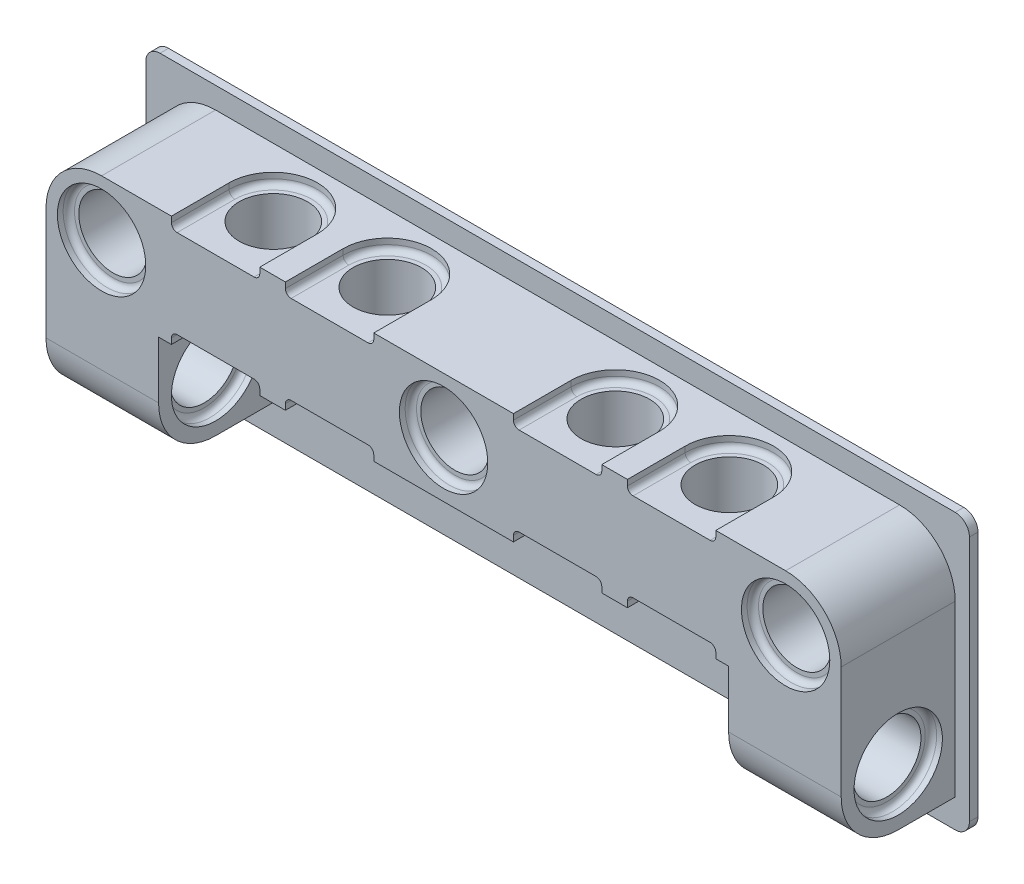
from build123d import *

# Parameters (mm, degrees)
SKETCH1_R               = 2.4
BOSS_EXTRUDE1_DEPTH     = 8
BOSS_EXTRUDE2_START     = 20
SKETCH2_R               = 2.4
BOSS_EXTRUDE2_DEPTH     = 7.9
BOSS_EXTRUDE3_DEPTH     = 0.6
SKETCH4_R               = 2.4
CUT_EXTRUDE1_DEPTH      = 34.051777562
CUT_EXTRUDE1_DEPTH_BACK = 34.051777562
CUT_EXTRUDE2_START      = 3.1
SKETCH5_R               = 3.1
CUT_EXTRUDE2_DEPTH      = 0.8
CUT_EXTRUDE3_START      = -3.9
SKETCH5_3_R             = 3.1
CUT_EXTRUDE3_DEPTH      = 0.8
CUT_EXTRUDE4_START      = 27.9
SKETCH6_R               = 3.1
CUT_EXTRUDE4_DEPTH      = 0.8
CUT_EXTRUDE5_START      = 20
SKETCH6_2_R             = 3.1
CUT_EXTRUDE5_DEPTH      = 0.8
CUT_EXTRUDE6_START      = 0.8
SKETCH7_R               = 3.1
CUT_EXTRUDE6_DEPTH      = 34.851777562
CUT_EXTRUDE7_START      = 7.2
SKETCH7_2_R             = 3.1
CUT_EXTRUDE7_DEPTH      = 0.8
FILLET1_R               = 0.4


with BuildPart() as part:
    # Sketch1 → Boss-Extrude1 (new body)
    with BuildSketch(Plane.XY):
        with BuildLine():
            Line((0, 3.9), (0, 2.4))
            ThreePointArc((0, 2.4), (2.4, 0), (0, -2.4))
            Line((0, -2.4), (0, -3.9))
            Line((0, -3.9), (24, -3.9))
            Line((24, -3.9), (27.9, -3.9))
            Line((27.9, -3.9), (27.9, 0))
            ThreePointArc((27.9, 0), (26.757716447, 2.757716447), (24, 3.9))
            Line((24, 3.9), (0, 3.9))
        make_face()
        with Locations((24, 0)):
            Circle(SKETCH1_R, mode=Mode.SUBTRACT)
    extrude(amount=BOSS_EXTRUDE1_DEPTH)

    # Sketch2 → Boss-Extrude2 (add)
    with BuildSketch(Plane(origin=(0, 0, 0), x_dir=(0, 0, -1), z_dir=(1, 0, 0)).offset(BOSS_EXTRUDE2_START)):
        with BuildLine():
            Line((0, -3.9), (0, -11.9))
            Line((0, -11.9), (-4, -11.9))
            ThreePointArc((-4, -11.9), (-6.828427125, -10.728427125), (-8, -7.9))
            Line((-8, -7.9), (-8, -3.9))
            Line((-8, -3.9), (0, -3.9))
        make_face()
        with Locations(Location((-4, -7.9, 0), (0, 0, 180))):
            Circle(SKETCH2_R, mode=Mode.SUBTRACT)
    extrude(amount=BOSS_EXTRUDE2_DEPTH)

    # Sketch3 → Boss-Extrude3 (add)
    with BuildSketch(Plane.XY):
        with BuildLine():
            Line((0, 5.4), (27.9, 5.4))
            ThreePointArc((27.9, 5.4), (28.607106781, 5.107106781), (28.9, 4.4))
            Line((28.9, 4.4), (28.9, -12.9))
            ThreePointArc((28.9, -12.9), (28.607106781, -13.607106781), (27.9, -13.9))
            Line((27.9, -13.9), (0, -13.9))
            Line((0, -13.9), (0, 5.4))
        make_face()
    extrude(amount=-BOSS_EXTRUDE3_DEPTH)

    # Sketch4 → Cut-Extrude1 (cut, two sides)
    with BuildSketch(Plane(origin=(0, 0, 0), x_dir=(1, 0, 0), z_dir=(0, 1, 0))) as cut_extrude1_sk:
        with Locations(Location((8, -3.95, 0), (0, 0, 270))):
            Circle(SKETCH4_R)
        with Locations(Location((16, -3.95, 0), (0, 0, 270))):
            Circle(SKETCH4_R)
    extrude(amount=CUT_EXTRUDE1_DEPTH, mode=Mode.SUBTRACT)
    extrude(cut_extrude1_sk.sketch, amount=-CUT_EXTRUDE1_DEPTH_BACK, mode=Mode.SUBTRACT)

    # Sketch5 → Cut-Extrude2 (cut)
    with BuildSketch(Plane(origin=(0, 0, 0), x_dir=(1, 0, 0), z_dir=(0, 1, 0)).offset(CUT_EXTRUDE2_START)):
        with BuildLine():
            ThreePointArc((11.1, -3.95), (8, -7.05), (4.9, -3.95))
            Line((4.9, -3.95), (4.9, -10.047053603))
            Line((4.9, -10.047053603), (11.1, -10.047053603))
            Line((11.1, -10.047053603), (11.1, -3.95))
        make_face()
        with Locations((8, -3.95)):
            Circle(SKETCH5_R)
        with BuildLine():
            ThreePointArc((19.1, -3.95), (16, -7.05), (12.9, -3.95))
            Line((12.9, -3.95), (12.9, -10.047053603))
            Line((12.9, -10.047053603), (19.1, -10.047053603))
            Line((19.1, -10.047053603), (19.1, -3.95))
        make_face()
        with Locations((16, -3.95)):
            Circle(SKETCH5_R)
    extrude(amount=CUT_EXTRUDE2_DEPTH, mode=Mode.SUBTRACT)

    # Sketch5_3 → Cut-Extrude3 (cut)
    with BuildSketch(Plane(origin=(0, 0, 0), x_dir=(1, 0, 0), z_dir=(0, 1, 0)).offset(CUT_EXTRUDE3_START)):
        with Locations((8, -3.95)):
            Circle(SKETCH5_3_R)
        with BuildLine():
            ThreePointArc((11.1, -3.95), (8, -7.05), (4.9, -3.95))
            Line((4.9, -3.95), (4.9, -10.047053603))
            Line((4.9, -10.047053603), (11.1, -10.047053603))
            Line((11.1, -10.047053603), (11.1, -3.95))
        make_face()
        with Locations((16, -3.95)):
            Circle(SKETCH5_3_R)
        with BuildLine():
            ThreePointArc((19.1, -3.95), (16, -7.05), (12.9, -3.95))
            Line((12.9, -3.95), (12.9, -10.047053603))
            Line((12.9, -10.047053603), (19.1, -10.047053603))
            Line((19.1, -10.047053603), (19.1, -3.95))
        make_face()
    extrude(amount=CUT_EXTRUDE3_DEPTH, mode=Mode.SUBTRACT)

    # Sketch6 → Cut-Extrude4 (cut)
    with BuildSketch(Plane(origin=(0, 0, 0), x_dir=(0, 0, -1), z_dir=(1, 0, 0)).offset(CUT_EXTRUDE4_START)):
        with Locations(Location((-4, -7.9, 0), (0, 0, 180))):
            Circle(SKETCH6_R)
    extrude(amount=-CUT_EXTRUDE4_DEPTH, mode=Mode.SUBTRACT)

    # Sketch6_2 → Cut-Extrude5 (cut)
    with BuildSketch(Plane(origin=(0, 0, 0), x_dir=(0, 0, -1), z_dir=(1, 0, 0)).offset(CUT_EXTRUDE5_START)):
        with Locations(Location((-4, -7.9, 0), (0, 0, 180))):
            Circle(SKETCH6_2_R)
    extrude(amount=CUT_EXTRUDE5_DEPTH, mode=Mode.SUBTRACT)

    # Sketch7 → Cut-Extrude6 (cut, through all)
    with BuildSketch(Plane.XY.offset(CUT_EXTRUDE6_START)):
        with Locations((24, 0)):
            Circle(SKETCH7_R)
        with BuildLine():
            Line((0, 3.1), (0, -3.1))
            ThreePointArc((0, -3.1), (3.1, 0), (0, 3.1))
        make_face()
    extrude(amount=-CUT_EXTRUDE6_DEPTH, mode=Mode.SUBTRACT)

    # Sketch7_2 → Cut-Extrude7 (cut)
    with BuildSketch(Plane.XY.offset(CUT_EXTRUDE7_START)):
        with Locations((24, 0)):
            Circle(SKETCH7_2_R)
        with BuildLine():
            Line((0, 3.1), (0, -3.1))
            ThreePointArc((0, -3.1), (3.1, 0), (0, 3.1))
        make_face()
    extrude(amount=CUT_EXTRUDE7_DEPTH, mode=Mode.SUBTRACT)

    # Fillet1
    fillet1_edges = [part.edges().sort_by_distance(p)[0] for p in [
        (16, 3.1, 0.85),
        (4.9, -3.1, 5.975),
        (11.1, -3.1, 5.975),
        (8, -3.1, 0.85),
        (12.9, -3.1, 5.975),
        (19.1, -3.1, 5.975),
        (16, -3.1, 0.85),
        (27.1, -7.9, 0.9),
        (20.8, -7.9, 0.9),
        (20.9, 0, 0.8),
        (3.1, 0, 0.8),
        (20.9, 0, 7.2),
        (3.1, 0, 7.2),
        (11.1, 3.1, 5.975),
        (4.9, 3.1, 5.975),
        (8, 3.1, 0.85),
        (19.1, 3.1, 5.975),
        (12.9, 3.1, 5.975),
    ]]
    fillet(fillet1_edges, radius=FILLET1_R)

    # Mirror1: part across plane


with BuildPart() as part_1:
    add(part.part)
    add(part.part.mirror(Plane(origin=(0, 0, 0), x_dir=(0, 0, 1), z_dir=(1, 0, 0))))


solid = part_1.part
